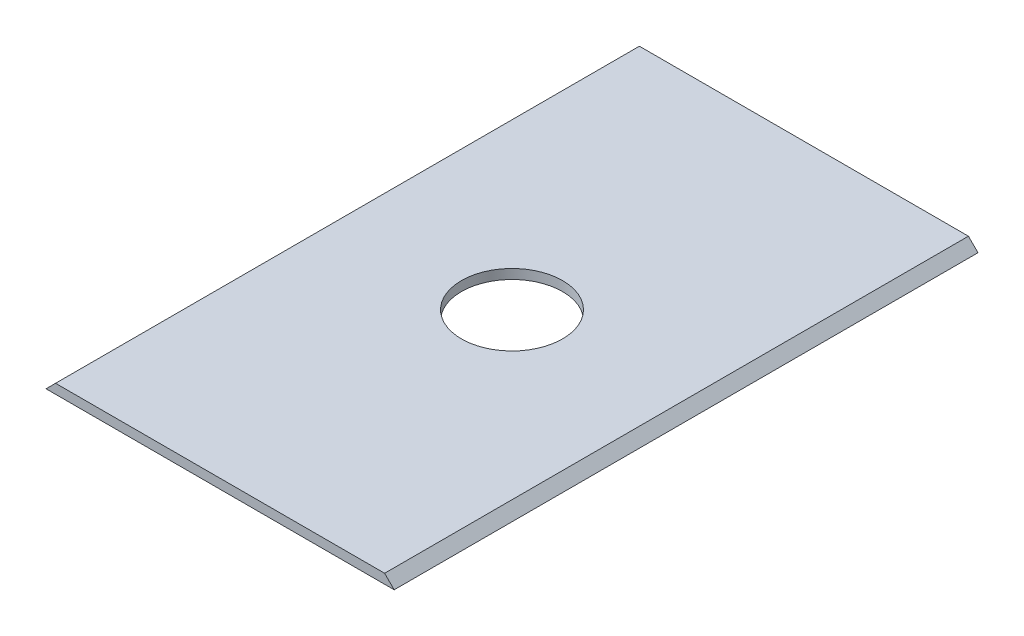
from build123d import *

# Parameters (mm, degrees)
BOSS_EXTRUDE1_DEPTH = 110
SKETCH2_R           = 9.525
CUT_EXTRUDE1_DEPTH  = 2.8


with BuildPart() as part:
    # Sketch1 → Boss-Extrude1 (new body)
    with BuildSketch(Plane.XY):
        Polygon((0, 0), (65.6, 0), (63.8, 1.8), (1.8, 1.8), align=None)
    extrude(amount=BOSS_EXTRUDE1_DEPTH)

    # Sketch2 → Cut-Extrude1 (cut, through all)
    with BuildSketch(Plane(origin=(0, 1.8, 0), x_dir=(1, 0, 0), z_dir=(0, 1, 0))):
        with Locations((32.8, -55)):
            Circle(SKETCH2_R)
    extrude(amount=-CUT_EXTRUDE1_DEPTH, mode=Mode.SUBTRACT)


solid = part.part
